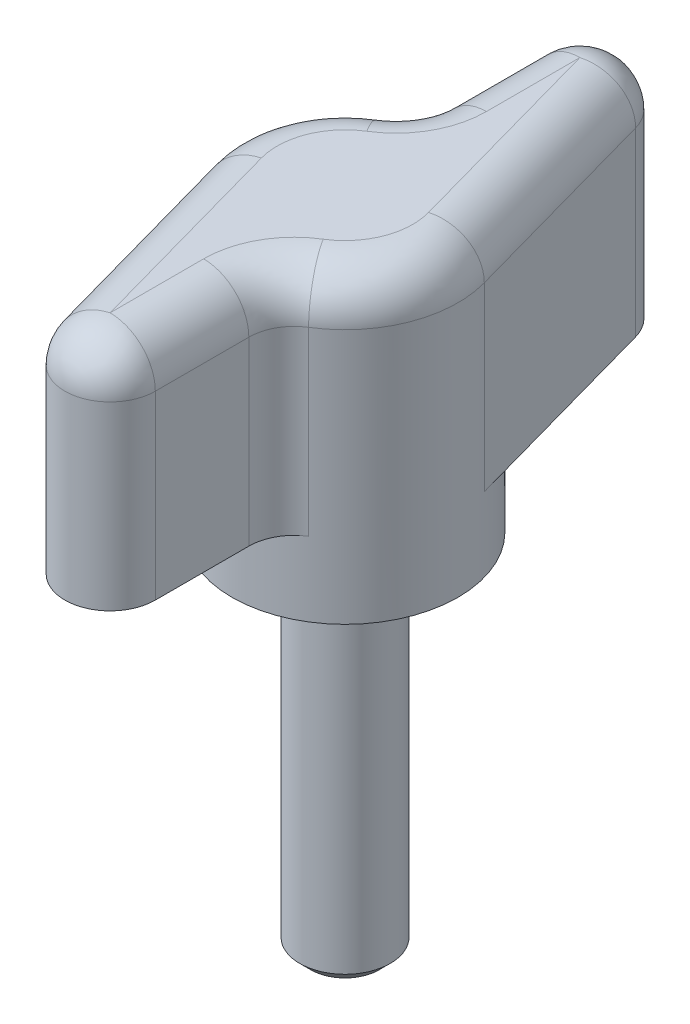
from build123d import *

# Parameters (mm, degrees)
SKETCH1_R         = 7.9375
EXTRUDE1_DEPTH    = 21.082
EXTRUDE2_DEPTH    = 15.875
CIRPATTERN4_COUNT = 2
FILLET1_R         = 3.175
SKETCH7_R         = 3.175
EXTRUDE3_DEPTH    = 25.4
CHAMFER1_SIZE     = 0.762


with BuildPart() as part:
    # Sketch1 → Extrude1 (new body)
    with BuildSketch(Plane(origin=(0, 0, 0), x_dir=(1, 0, 0), z_dir=(0, 1, 0))):
        Circle(SKETCH1_R)
    extrude(amount=EXTRUDE1_DEPTH)

    # Sketch2 → Extrude2 (add)
    with BuildSketch(Plane(origin=(0, 21.082, 0), x_dir=(-1, 0, 0), z_dir=(0, 1, 0))):
        with BuildLine():
            Line((2.68951844, -16.002), (2.68951844, -7.467958008))
            ThreePointArc((2.68951844, -7.467958008), (-3.642086896, -7.052595926), (-7.64626831, -2.130372546))
            Line((-7.64626831, -2.130372546), (-3.543988884, -16.854149018))
            ThreePointArc((-3.543988884, -16.854149018), (-0.055444209, -19.147742023), (2.68951844, -16.002))
        make_face()
    extrude2 = extrude(amount=-EXTRUDE2_DEPTH)

    # CirPattern4: Extrude2 ×2 about axis
    cirpattern4_axis = Axis((0, 0, 0), (0, 1, 0))
    for i in range(1, CIRPATTERN4_COUNT):
        add(extrude2.rotate(cirpattern4_axis, i * 360 / CIRPATTERN4_COUNT))

    # Fillet1
    fillet1_edges = [part.edges().sort_by_distance(p)[0] for p in [
        (6.494303614, 21.082, 4.563762353),
        (2.68951844, 13.1445, 7.467958008),
        (-0.055444209, 21.082, 19.147742023),
        (2.68951844, 21.082, 11.734979004),
        (-5.595128597, 21.082, 9.492260782),
        (-7.052595926, 21.082, -3.642086896),
        (-2.68951844, 13.1445, -7.467958008),
        (0.055444209, 21.082, -19.147742023),
        (-2.68951844, 21.082, -11.734979004),
        (5.595128597, 21.082, -9.492260782),
    ]]
    fillet(fillet1_edges, radius=FILLET1_R)


with BuildPart() as body_2:
    # Sketch7 → Extrude3 (new body)
    with BuildSketch(Plane.XZ):
        Circle(SKETCH7_R)
    extrude(amount=EXTRUDE3_DEPTH)

    # Chamfer1
    chamfer1_edges = [body_2.edges().sort_by_distance(p)[0] for p in [
        (-3.175, -25.4, 0),
    ]]
    chamfer(chamfer1_edges, length=CHAMFER1_SIZE)


solid = Compound([part.part, body_2.part])
